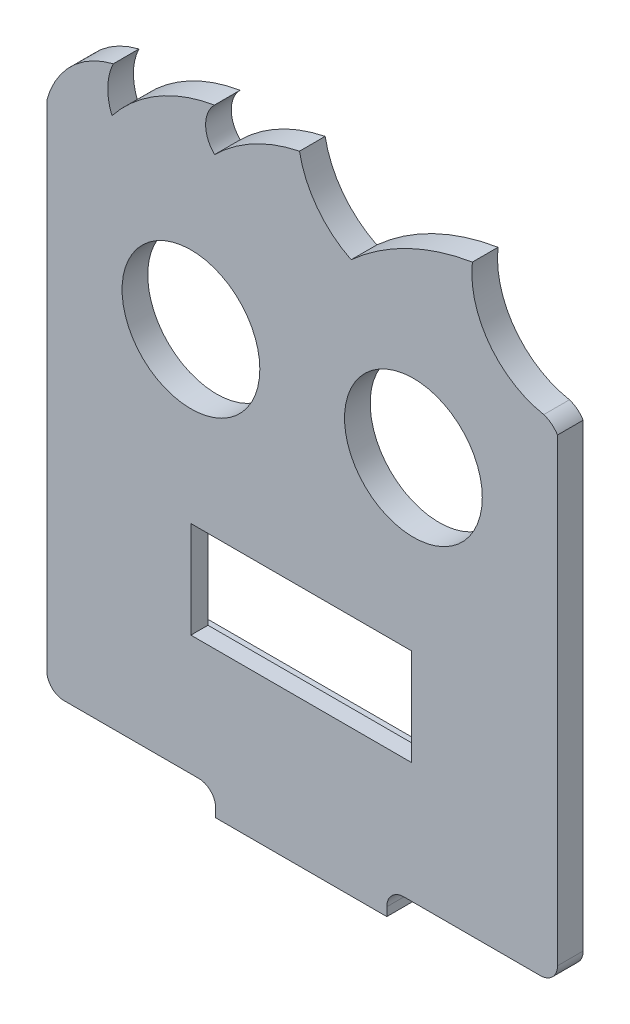
from build123d import *

# Parameters (mm, degrees)
MODEL_R                 = 8.05
MODEL_W                 = 25.8
MODEL_H                 = 11.3
SALIENTE_EXTRUIR1_DEPTH = 3
CROQUIS2_W              = 20
CROQUIS2_H              = 3
SALIENTE_EXTRUIR2_DEPTH = 8
CROQUIS3_R              = 1.5
CORTAR_EXTRUIR1_DEPTH   = 3
CROQUIS4_R              = 2.25
CORTAR_EXTRUIR2_DEPTH   = 1
REDONDEO1_R             = 2
CROQUIS5_W              = 38.3
CROQUIS5_H              = 12.1
CORTAR_EXTRUIR3_DEPTH   = 1


with BuildPart() as part:
    # Model → Saliente-Extruir1 (new body)
    with BuildSketch(Plane.XY):
        with BuildLine():
            Line((50.589823504, -56.020997464), (70.589823504, -56.020997464))
            Line((70.589823504, -56.020997464), (70.589823504, -55.020997464))
            ThreePointArc((70.589823504, -55.020997464), (71.175609941, -53.606783901), (72.589823504, -53.020997464))
            Line((72.589823504, -53.020997464), (88.542347513, -53.020997464))
            ThreePointArc((88.542347513, -53.020997464), (89.956561076, -52.435211026), (90.542347513, -51.020997464))
            Line((90.542347513, -51.020997464), (90.542347513, 2.706709465))
            ThreePointArc((90.542347513, 2.706709465), (89.85153081, 3.480899542), (88.938302171, 3.973455574))
            ThreePointArc((88.938302171, 3.973455574), (82.554576883, 7.967186508), (80.590162534, 15.236499516))
            ThreePointArc((80.590162534, 15.236499516), (73.013912202, 12.831206377), (66.42202871, 8.389126209))
            ThreePointArc((66.42202871, 8.389126209), (62.462620999, 11.66270114), (60.385206297, 16.361376528))
            ThreePointArc((60.385206297, 16.361376528), (55.037159481, 14.426569266), (50.459652092, 11.051438157))
            ThreePointArc((50.459652092, 11.051438157), (49.412602259, 13.546636971), (50.436598222, 16.051385009))
            ThreePointArc((50.436598222, 16.051385009), (43.797798117, 13.634815248), (38.469001196, 8.99613013))
            ThreePointArc((38.469001196, 8.99613013), (37.974300587, 11.673196605), (38.616025483, 14.318872844))
            ThreePointArc((38.616025483, 14.318872844), (33.704473328, 11.607826814), (30.85334667, 6.776244059))
            Line((30.85334667, 6.776244059), (30.85334667, -51.020997464))
            ThreePointArc((30.85334667, -51.020997464), (31.439133108, -52.435211026), (32.85334667, -53.020997464))
            Line((32.85334667, -53.020997464), (48.589823504, -53.020997464))
            ThreePointArc((48.589823504, -53.020997464), (50.004037066, -53.606783901), (50.589823504, -55.020997464))
            Line((50.589823504, -55.020997464), (50.589823504, -56.020997464))
        make_face()
        with Locations((47.698959583, -8.020997464)):
            Circle(MODEL_R, mode=Mode.SUBTRACT)
        with Locations((73.698959582, -8.020997464)):
            Circle(MODEL_R, mode=Mode.SUBTRACT)
        with Locations((60.589823504, -33.326919867)):
            Rectangle(MODEL_W, MODEL_H, mode=Mode.SUBTRACT)
    extrude(amount=SALIENTE_EXTRUIR1_DEPTH)

    # Croquis2 → Saliente-Extruir2 (add)
    with BuildSketch(Plane(origin=(0, 0, 0), x_dir=(-1, 0, 0), z_dir=(0, 0, -1))):
        with Locations((-60.589823504, -54.520997464)):
            Rectangle(CROQUIS2_W, CROQUIS2_H)
    extrude(amount=SALIENTE_EXTRUIR2_DEPTH)

    # Croquis3 → Cortar-Extruir1 (cut)
    with BuildSketch(Plane(origin=(0, -53.020997464, 0), x_dir=(1, 0, 0), z_dir=(0, 1, 0))):
        with Locations((66.589823504, 3.5)):
            Circle(CROQUIS3_R)
        with Locations((54.589823504, 3.5)):
            Circle(CROQUIS3_R)
    extrude(amount=-CORTAR_EXTRUIR1_DEPTH, mode=Mode.SUBTRACT)

    # Croquis4 → Cortar-Extruir2 (cut)
    with BuildSketch(Plane(origin=(0, -53.020997464, 0), x_dir=(1, 0, 0), z_dir=(0, 1, 0))):
        with Locations((66.589823504, 3.5)):
            Circle(CROQUIS4_R)
        with Locations((54.589823504, 3.5)):
            Circle(CROQUIS4_R)
    extrude(amount=-CORTAR_EXTRUIR2_DEPTH, mode=Mode.SUBTRACT)

    # Redondeo1
    redondeo1_edges = [part.edges().sort_by_distance(p)[0] for p in [
        (50.589823504, -54.520997464, -8),
        (70.589823504, -54.520997464, -8),
    ]]
    fillet(redondeo1_edges, radius=REDONDEO1_R)

    # Croquis5 → Cortar-Extruir3 (cut)
    with BuildSketch(Plane(origin=(0, 0, 0), x_dir=(-1, 0, 0), z_dir=(0, 0, -1))):
        with Locations((-61.789823504, -33.326919867)):
            Rectangle(CROQUIS5_W, CROQUIS5_H)
    extrude(amount=-CORTAR_EXTRUIR3_DEPTH, mode=Mode.SUBTRACT)


solid = part.part
